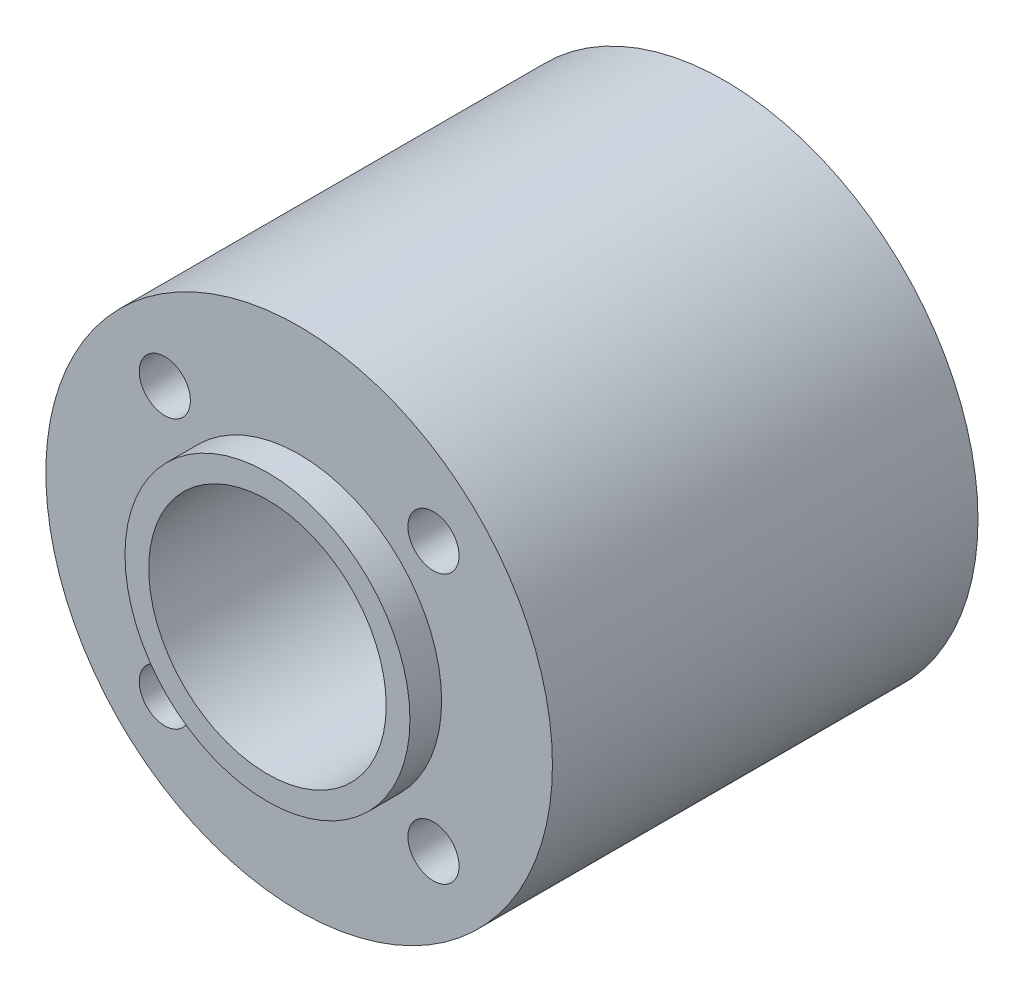
from build123d import *

# Parameters (mm, degrees)
SKETCH1_R           = 16
BOSS_EXTRUDE1_DEPTH = 26.88
SKETCH4_R           = 9
BOSS_EXTRUDE2_DEPTH = 2
SKETCH5_R           = 9
BOSS_EXTRUDE3_DEPTH = 2
SKETCH6_R           = 7.5
CUT_EXTRUDE2_DEPTH  = 31.88
SKETCH7_R           = 1.615
CUT_EXTRUDE3_DEPTH  = 29.88


with BuildPart() as part:
    # Sketch1 → Boss-Extrude1 (new body)
    with BuildSketch(Plane.XY):
        Circle(SKETCH1_R)
    extrude(amount=BOSS_EXTRUDE1_DEPTH)

    # Sketch4 → Boss-Extrude2 (add)
    with BuildSketch(Plane.XY.offset(26.88)):
        Circle(SKETCH4_R)
    extrude(amount=BOSS_EXTRUDE2_DEPTH)

    # Sketch5 → Boss-Extrude3 (add)
    with BuildSketch(Plane(origin=(0, 0, 0), x_dir=(-1, 0, 0), z_dir=(0, 0, -1))):
        Circle(SKETCH5_R)
    extrude(amount=BOSS_EXTRUDE3_DEPTH)

    # Sketch6 → Cut-Extrude2 (cut, through all)
    with BuildSketch(Plane.XY.offset(28.88)):
        Circle(SKETCH6_R)
    extrude(amount=-CUT_EXTRUDE2_DEPTH, mode=Mode.SUBTRACT)

    # Sketch7 → Cut-Extrude3 (cut, through all)
    with BuildSketch(Plane.XY.offset(26.88)):
        with Locations((-8.485, 8.485)):
            Circle(SKETCH7_R)
        with Locations((8.485, 8.485)):
            Circle(SKETCH7_R)
        with Locations((8.485, -8.485)):
            Circle(SKETCH7_R)
        with Locations((-8.485, -8.485)):
            Circle(SKETCH7_R)
    extrude(amount=-CUT_EXTRUDE3_DEPTH, mode=Mode.SUBTRACT)


solid = part.part
